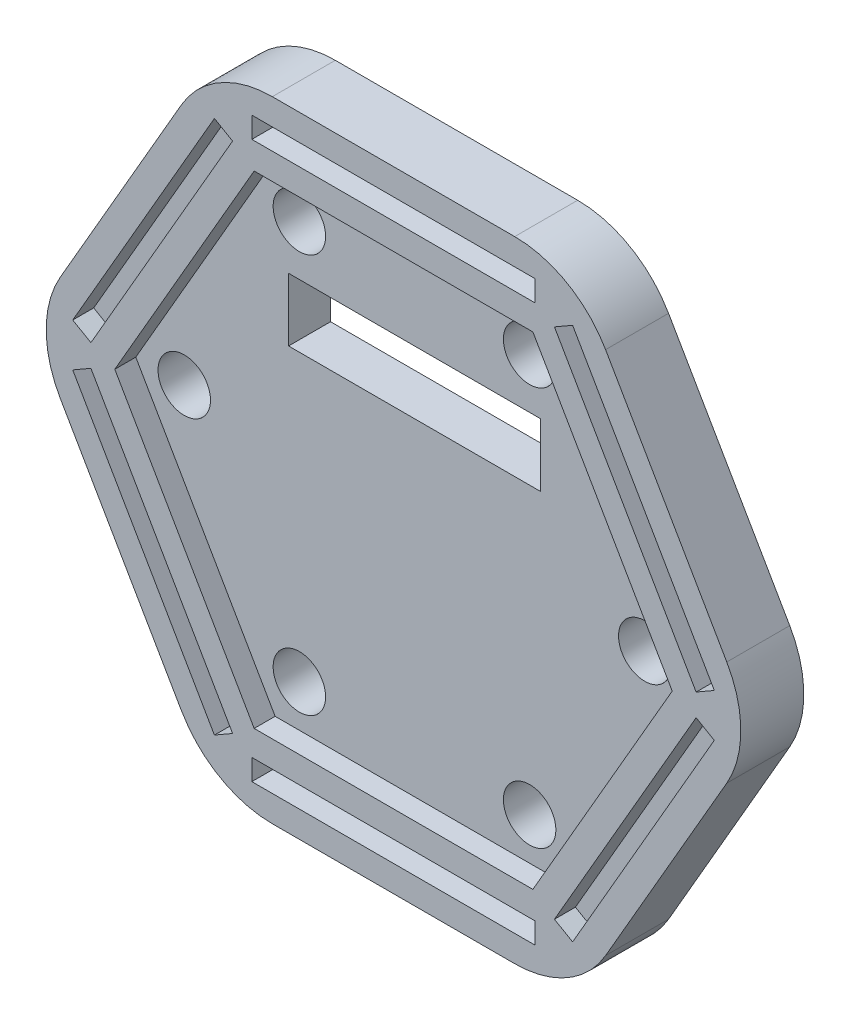
from build123d import *

# Parameters (mm, degrees)
EXTRUDE_1_DEPTH     = 2
EXTRUDE_2_DEPTH     = 1
EXTRUDE_3_DEPTH     = 1
SKETCH_4_W          = 12
SKETCH_4_H          = 3
CUT_EXTRUDE_1_DEPTH = 3
SKETCH_5_R          = 1.25
CUT_EXTRUDE_2_DEPTH = 3
EXTRUDE_5_REACH     = 5
FILLET_1_R          = 5


with BuildPart() as part:
    # Эскиз1 → Бобышка-Вытянуть1 (new body)
    with BuildSketch(Plane.XY):
        Polygon((8.660254038, 15), (-8.660254038, 15), (-17.320508076, 0), (-8.660254038, -15), (8.660254038, -15), (17.320508076, 0), align=None)
    extrude(amount=EXTRUDE_1_DEPTH)

    # Эскиз2 → Бобышка-Вытянуть2 (add)
    with BuildSketch(Plane.XY.offset(2)):
        Polygon((8.660254038, 15), (-8.660254038, 15), (-17.320508076, 0), (-8.660254038, -15), (8.660254038, -15), (17.320508076, 0), align=None)
        Polygon((7.938566201, 13.75), (-7.938566201, 13.75), (-15.877132403, 0), (-7.938566201, -13.75), (7.938566201, -13.75), (15.877132403, 0), align=None, mode=Mode.SUBTRACT)
    extrude(amount=EXTRUDE_2_DEPTH)

    # Эскиз3 → Бобышка-Вытянуть3 (add)
    with BuildSketch(Plane.XY.offset(2)):
        Polygon((7.361215932, 12.75), (-7.361215932, 12.75), (-14.722431864, 0), (-7.361215932, -12.75), (7.361215932, -12.75), (14.722431864, 0), align=None)
        Polygon((6.639528096, 11.5), (-6.639528096, 11.5), (-13.279056191, 0), (-6.639528096, -11.5), (6.639528096, -11.5), (13.279056191, 0), align=None, mode=Mode.SUBTRACT)
    extrude(amount=EXTRUDE_3_DEPTH)

    # Эскиз4 → Вырез-Вытянуть1 (cut, through all)
    with BuildSketch(Plane.XY.offset(2)):
        with Locations((0, 5.6)):
            Rectangle(SKETCH_4_W, SKETCH_4_H)
    extrude(amount=-CUT_EXTRUDE_1_DEPTH, mode=Mode.SUBTRACT)

    # Эскиз5 → Вырез-Вытянуть2 (cut, through all)
    with BuildSketch(Plane.XY.offset(2)):
        with Locations((-5.484827557, 9.5)):
            Circle(SKETCH_5_R)
        with Locations((5.484827557, 9.5)):
            Circle(SKETCH_5_R)
        with Locations((10.969655115, 0)):
            Circle(SKETCH_5_R)
        with Locations((5.484827557, -9.5)):
            Circle(SKETCH_5_R)
        with Locations((-5.484827557, -9.5)):
            Circle(SKETCH_5_R)
        with Locations((-10.969655115, 0)):
            Circle(SKETCH_5_R)
    extrude(amount=-CUT_EXTRUDE_2_DEPTH, mode=Mode.SUBTRACT)

    # Эскиз7 → Бобышка-Вытянуть5 (add, up to next)
    with BuildSketch(Plane.XY.offset(3), mode=Mode.PRIVATE) as extrude_5_sk1:
        Polygon((-6.75, 11.691342951), (-9.615381057, 13.345671476), (-8.660254038, 15), (-6.75, 15), align=None)
    extrude_5_tool1 = extrude(extrude_5_sk1.sketch, amount=-EXTRUDE_5_REACH, mode=Mode.PRIVATE) - part.part
    add(extrude_5_tool1.solids().sort_by_distance((-7.864315, 13.621393, 3))[0])
    # Эскиз7 → Бобышка-Вытянуть5 (add, up to next)
    with BuildSketch(Plane.XY.offset(3), mode=Mode.PRIVATE) as extrude_5_sk2:
        Polygon((6.75, 11.691342951), (6.75, 15), (8.660254038, 15), (9.615381057, 13.345671476), align=None)
    extrude_5_tool2 = extrude(extrude_5_sk2.sketch, amount=-EXTRUDE_5_REACH, mode=Mode.PRIVATE) - part.part
    add(extrude_5_tool2.solids().sort_by_distance((7.864315, 13.621393, 3))[0])
    # Эскиз7 → Бобышка-Вытянуть5 (add, up to next)
    with BuildSketch(Plane.XY.offset(3), mode=Mode.PRIVATE) as extrude_5_sk3:
        Polygon((13.5, 0), (16.365381057, 1.654328524), (17.320508076, 0), (16.365381057, -1.654328524), align=None)
    extrude_5_tool3 = extrude(extrude_5_sk3.sketch, amount=-EXTRUDE_5_REACH, mode=Mode.PRIVATE) - part.part
    add(extrude_5_tool3.solids().sort_by_distance((15.72863, 0, 3))[0])
    # Эскиз7 → Бобышка-Вытянуть5 (add, up to next)
    with BuildSketch(Plane.XY.offset(3), mode=Mode.PRIVATE) as extrude_5_sk4:
        Polygon((6.75, -11.691342951), (9.615381057, -13.345671476), (8.660254038, -15), (6.75, -15), align=None)
    extrude_5_tool4 = extrude(extrude_5_sk4.sketch, amount=-EXTRUDE_5_REACH, mode=Mode.PRIVATE) - part.part
    add(extrude_5_tool4.solids().sort_by_distance((7.864315, -13.621393, 3))[0])
    # Эскиз7 → Бобышка-Вытянуть5 (add, up to next)
    with BuildSketch(Plane.XY.offset(3), mode=Mode.PRIVATE) as extrude_5_sk5:
        Polygon((-6.75, -11.691342951), (-6.75, -15), (-8.660254038, -15), (-9.615381057, -13.345671476), align=None)
    extrude_5_tool5 = extrude(extrude_5_sk5.sketch, amount=-EXTRUDE_5_REACH, mode=Mode.PRIVATE) - part.part
    add(extrude_5_tool5.solids().sort_by_distance((-7.864315, -13.621393, 3))[0])
    # Эскиз7 → Бобышка-Вытянуть5 (add, up to next)
    with BuildSketch(Plane.XY.offset(3), mode=Mode.PRIVATE) as extrude_5_sk6:
        Polygon((-13.5, 0), (-16.365381057, -1.654328524), (-17.320508076, 0), (-16.365381057, 1.654328524), align=None)
    extrude_5_tool6 = extrude(extrude_5_sk6.sketch, amount=-EXTRUDE_5_REACH, mode=Mode.PRIVATE) - part.part
    add(extrude_5_tool6.solids().sort_by_distance((-15.72863, 0, 3))[0])

    # Скругление1
    fillet_1_edges = [part.edges().sort_by_distance(p)[0] for p in [
        (17.320508076, 0, 1.5),
        (8.660254038, -15, 1.5),
        (-8.660254038, -15, 1.5),
        (-17.320508076, 0, 1.5),
        (-8.660254038, 15, 1.5),
        (8.660254038, 15, 1.5),
    ]]
    fillet(fillet_1_edges, radius=FILLET_1_R)


solid = part.part
